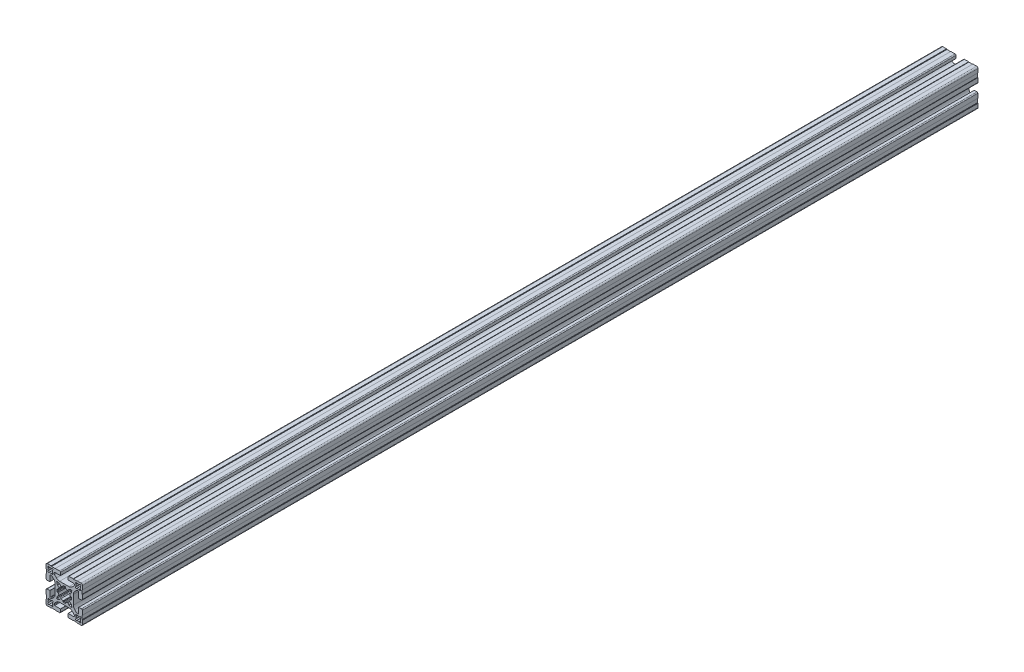
from build123d import *

# Parameters (mm, degrees)
RESSALTO_EXTRUS_O1_DEPTH = 490


with BuildPart() as part:
    # Esboço1 → Ressalto-extrusão1 (new body, symmetric)
    with BuildSketch(Plane.XY):
        with BuildLine():
            Line((4.14998475, -18.79998475), (4.14998475, -15.899980918))
            ThreePointArc((4.14998475, -15.899980918), (4.179274222, -15.829270089), (4.249985176, -15.799980918))
            Line((4.249985176, -15.799980918), (10.499997871, -15.800007531))
            ThreePointArc((10.499997871, -15.800007531), (10.853552638, -15.653561674), (11, -15.300007531))
            Line((11, -15.300007531), (11, -14.449747468))
            ThreePointArc((11, -14.449747468), (10.885819299, -13.87572232), (10.560660172, -13.389087297))
            Line((10.560660172, -13.389087297), (8.636038969, -11.464466094))
            ThreePointArc((8.636038969, -11.464466094), (7.013922225, -10.380602337), (5.100505063, -10))
            Line((5.100505063, -10), (0, -10))
            Line((0, -10), (-5.100505063, -10))
            ThreePointArc((-5.100505063, -10), (-7.013922225, -10.380602337), (-8.636038969, -11.464466094))
            Line((-8.636038969, -11.464466094), (-10.560660172, -13.389087297))
            ThreePointArc((-10.560660172, -13.389087297), (-10.885819299, -13.87572232), (-11, -14.449747468))
            Line((-11, -14.449747468), (-11, -15.300007531))
            ThreePointArc((-11, -15.300007531), (-10.853552638, -15.653561674), (-10.499997871, -15.800007531))
            Line((-10.499997871, -15.800007531), (-4.249985176, -15.799980918))
            ThreePointArc((-4.249985176, -15.799980918), (-4.179274222, -15.829270089), (-4.14998475, -15.899980918))
            Line((-4.14998475, -15.899980918), (-4.14998475, -18.79998475))
            ThreePointArc((-4.14998475, -18.79998475), (-4.442876463, -19.507090026), (-5.149980492, -19.79998475))
            Line((-5.149980492, -19.79998475), (-9.79996495, -19.80000455))
            Line((-9.79996495, -19.80000455), (-9.99998475, -19.59998475))
            Line((-9.99998475, -19.59998475), (-13.99998475, -19.59998475))
            Line((-13.99998475, -19.59998475), (-14.40000475, -20.00000475))
            Line((-14.40000475, -20.00000475), (-18.50000475, -20.00000475))
            ThreePointArc((-18.50000475, -20.00000475), (-19.560664922, -19.560664922), (-20.00000475, -18.50000475))
            Line((-20.00000475, -18.50000475), (-20.00000475, -14.40000475))
            Line((-20.00000475, -14.40000475), (-19.59998475, -13.99998475))
            Line((-19.59998475, -13.99998475), (-19.59998475, -9.99998475))
            Line((-19.59998475, -9.99998475), (-19.800004551, -9.799964949))
            Line((-19.800004551, -9.799964949), (-19.799984751, -5.149980488))
            ThreePointArc((-19.799984751, -5.149980488), (-19.507090026, -4.442876459), (-18.79998475, -4.149984746))
            Line((-18.79998475, -4.149984746), (-15.899980918, -4.149984746))
            ThreePointArc((-15.899980918, -4.149984746), (-15.829270089, -4.179274218), (-15.799980918, -4.249985172))
            Line((-15.799980918, -4.249985172), (-15.800007532, -10.499997871))
            ThreePointArc((-15.800007532, -10.499997871), (-15.653561675, -10.853552638), (-15.300007532, -11))
            Line((-15.300007532, -11), (-14.449747468, -11))
            ThreePointArc((-14.449747468, -11), (-13.87572232, -10.885819298), (-13.389087297, -10.560660171))
            Line((-13.389087297, -10.560660171), (-11.464466094, -8.636038969))
            ThreePointArc((-11.464466094, -8.636038969), (-10.380602337, -7.013922225), (-10, -5.100505063))
            Line((-10, -5.100505063), (-10, 0))
            Line((-10, 0), (-10, 5.100505064))
            ThreePointArc((-10, 5.100505064), (-10.380602337, 7.013922225), (-11.464466094, 8.63603897))
            Line((-11.464466094, 8.63603897), (-13.389087297, 10.560660172))
            ThreePointArc((-13.389087297, 10.560660172), (-13.87572232, 10.885819299), (-14.449747468, 11))
            Line((-14.449747468, 11), (-15.300007532, 11))
            ThreePointArc((-15.300007532, 11), (-15.653561675, 10.853552638), (-15.800007532, 10.499997871))
            Line((-15.800007532, 10.499997871), (-15.799980918, 4.249985172))
            ThreePointArc((-15.799980918, 4.249985172), (-15.829270089, 4.179274219), (-15.899980918, 4.149984747))
            Line((-15.899980918, 4.149984747), (-18.79998475, 4.149984747))
            ThreePointArc((-18.79998475, 4.149984747), (-19.507090026, 4.44287646), (-19.799984751, 5.149980488))
            Line((-19.799984751, 5.149980488), (-19.800004551, 9.79996495))
            Line((-19.800004551, 9.79996495), (-19.59998475, 9.999984751))
            Line((-19.59998475, 9.999984751), (-19.59998475, 13.999984751))
            Line((-19.59998475, 13.999984751), (-20.00000475, 14.400004751))
            Line((-20.00000475, 14.400004751), (-20.00000475, 18.500004751))
            ThreePointArc((-20.00000475, 18.500004751), (-19.560664922, 19.560664922), (-18.50000475, 20.000004751))
            Line((-18.50000475, 20.000004751), (-14.40000475, 20.000004751))
            Line((-14.40000475, 20.000004751), (-13.99998475, 19.599984751))
            Line((-13.99998475, 19.599984751), (-9.99998475, 19.599984751))
            Line((-9.99998475, 19.599984751), (-9.79996495, 19.800004551))
            Line((-9.79996495, 19.800004551), (-5.149980492, 19.799984751))
            ThreePointArc((-5.149980492, 19.799984751), (-4.442876463, 19.507090026), (-4.14998475, 18.799984751))
            Line((-4.14998475, 18.799984751), (-4.14998475, 15.899980918))
            ThreePointArc((-4.14998475, 15.899980918), (-4.179274222, 15.82927009), (-4.249985176, 15.799980918))
            Line((-4.249985176, 15.799980918), (-10.499997871, 15.800007531))
            ThreePointArc((-10.499997871, 15.800007531), (-10.853552638, 15.653561675), (-11, 15.300007531))
            Line((-11, 15.300007531), (-11, 14.449747469))
            ThreePointArc((-11, 14.449747469), (-10.885819299, 13.87572232), (-10.560660172, 13.389087297))
            Line((-10.560660172, 13.389087297), (-8.636038969, 11.464466095))
            ThreePointArc((-8.636038969, 11.464466095), (-7.013922225, 10.380602338), (-5.100505063, 10.000000001))
            Line((-5.100505063, 10.000000001), (0, 10.000000001))
            Line((0, 10.000000001), (5.100505063, 10.000000001))
            ThreePointArc((5.100505063, 10.000000001), (7.013922225, 10.380602338), (8.636038969, 11.464466095))
            Line((8.636038969, 11.464466095), (10.560660172, 13.389087297))
            ThreePointArc((10.560660172, 13.389087297), (10.885819299, 13.87572232), (11, 14.449747469))
            Line((11, 14.449747469), (11, 15.300007531))
            ThreePointArc((11, 15.300007531), (10.853552638, 15.653561675), (10.499997871, 15.800007531))
            Line((10.499997871, 15.800007531), (4.249985176, 15.799980918))
            ThreePointArc((4.249985176, 15.799980918), (4.179274222, 15.82927009), (4.14998475, 15.899980918))
            Line((4.14998475, 15.899980918), (4.14998475, 18.799984751))
            ThreePointArc((4.14998475, 18.799984751), (4.442876463, 19.507090026), (5.149980492, 19.799984751))
            Line((5.149980492, 19.799984751), (9.79996495, 19.800004551))
            Line((9.79996495, 19.800004551), (9.99998475, 19.599984751))
            Line((9.99998475, 19.599984751), (13.99998475, 19.599984751))
            Line((13.99998475, 19.599984751), (14.40000475, 20.000004751))
            Line((14.40000475, 20.000004751), (18.50000475, 20.000004751))
            ThreePointArc((18.50000475, 20.000004751), (19.560664922, 19.560664922), (20.00000475, 18.500004751))
            Line((20.00000475, 18.500004751), (20.00000475, 14.400004751))
            Line((20.00000475, 14.400004751), (19.59998475, 13.999984751))
            Line((19.59998475, 13.999984751), (19.59998475, 9.999984751))
            Line((19.59998475, 9.999984751), (19.800004551, 9.79996495))
            Line((19.800004551, 9.79996495), (19.799984751, 5.149980488))
            ThreePointArc((19.799984751, 5.149980488), (19.507090026, 4.44287646), (18.79998475, 4.149984747))
            Line((18.79998475, 4.149984747), (15.899980918, 4.149984747))
            ThreePointArc((15.899980918, 4.149984747), (15.829270089, 4.179274219), (15.799980918, 4.249985172))
            Line((15.799980918, 4.249985172), (15.800007532, 10.499997871))
            ThreePointArc((15.800007532, 10.499997871), (15.653561675, 10.853552638), (15.300007532, 11))
            Line((15.300007532, 11), (14.449747468, 11))
            ThreePointArc((14.449747468, 11), (13.87572232, 10.885819299), (13.389087297, 10.560660172))
            Line((13.389087297, 10.560660172), (11.464466094, 8.63603897))
            ThreePointArc((11.464466094, 8.63603897), (10.380602337, 7.013922225), (10, 5.100505064))
            Line((10, 5.100505064), (10, 0))
            Line((10, 0), (10, -5.100505063))
            ThreePointArc((10, -5.100505063), (10.380602337, -7.013922225), (11.464466094, -8.636038969))
            Line((11.464466094, -8.636038969), (13.389087297, -10.560660171))
            ThreePointArc((13.389087297, -10.560660171), (13.87572232, -10.885819298), (14.449747468, -11))
            Line((14.449747468, -11), (15.300007532, -11))
            ThreePointArc((15.300007532, -11), (15.653561675, -10.853552638), (15.800007532, -10.499997871))
            Line((15.800007532, -10.499997871), (15.799980918, -4.249985172))
            ThreePointArc((15.799980918, -4.249985172), (15.829270089, -4.179274218), (15.899980918, -4.149984746))
            Line((15.899980918, -4.149984746), (18.79998475, -4.149984746))
            ThreePointArc((18.79998475, -4.149984746), (19.507090026, -4.442876459), (19.799984751, -5.149980488))
            Line((19.799984751, -5.149980488), (19.800004551, -9.799964949))
            Line((19.800004551, -9.799964949), (19.59998475, -9.99998475))
            Line((19.59998475, -9.99998475), (19.59998475, -13.99998475))
            Line((19.59998475, -13.99998475), (20.00000475, -14.40000475))
            Line((20.00000475, -14.40000475), (20.00000475, -18.50000475))
            ThreePointArc((20.00000475, -18.50000475), (19.560664922, -19.560664922), (18.50000475, -20.00000475))
            Line((18.50000475, -20.00000475), (14.40000475, -20.00000475))
            Line((14.40000475, -20.00000475), (13.99998475, -19.59998475))
            Line((13.99998475, -19.59998475), (9.99998475, -19.59998475))
            Line((9.99998475, -19.59998475), (9.79996495, -19.80000455))
            Line((9.79996495, -19.80000455), (5.149980492, -19.79998475))
            ThreePointArc((5.149980492, -19.79998475), (4.442876463, -19.507090026), (4.14998475, -18.79998475))
        make_face()
        with BuildLine():
            Line((-5.31389005, -7.63550963), (-7.648765071, -8.261137506))
            ThreePointArc((-7.648765071, -8.261137506), (-8.131727984, -8.131727984), (-8.261137506, -7.64876507))
            Line((-8.261137506, -7.64876507), (-7.63550963, -5.313890049))
            ThreePointArc((-7.63550963, -5.313890049), (-7.568281523, -5.165514456), (-7.456927431, -5.046622902))
            Line((-7.456927431, -5.046622902), (-5.743958929, -3.73221594))
            ThreePointArc((-5.743958929, -3.73221594), (-6.328574798, -2.621381512), (-6.70066751, -1.422517109))
            Line((-6.70066751, -1.422517109), (-7.520425705, -1.314593895))
            ThreePointArc((-7.520425705, -1.314593895), (-7.812495975, -1.168604027), (-7.952173449, -0.873462896))
            ThreePointArc((-7.952173449, -0.873462896), (-8, 0), (-7.952173449, 0.873462896))
            ThreePointArc((-7.952173449, 0.873462896), (-7.812495975, 1.168604027), (-7.520425705, 1.314593895))
            Line((-7.520425705, 1.314593895), (-6.70066751, 1.422517109))
            ThreePointArc((-6.70066751, 1.422517109), (-6.328574798, 2.621381512), (-5.743958929, 3.73221594))
            Line((-5.743958929, 3.73221594), (-7.456927431, 5.046622902))
            ThreePointArc((-7.456927431, 5.046622902), (-7.568281523, 5.165514456), (-7.63550963, 5.313890049))
            Line((-7.63550963, 5.313890049), (-8.261137506, 7.64876507))
            ThreePointArc((-8.261137506, 7.64876507), (-8.131727984, 8.131727984), (-7.648765071, 8.261137506))
            Line((-7.648765071, 8.261137506), (-5.31389005, 7.63550963))
            ThreePointArc((-5.31389005, 7.63550963), (-5.165514456, 7.568281523), (-5.046622902, 7.456927431))
            Line((-5.046622902, 7.456927431), (-3.73221594, 5.743958929))
            ThreePointArc((-3.73221594, 5.743958929), (-2.621381512, 6.328574798), (-1.422517109, 6.70066751))
            Line((-1.422517109, 6.70066751), (-1.314593895, 7.520425705))
            ThreePointArc((-1.314593895, 7.520425705), (-1.168604027, 7.812495975), (-0.873462896, 7.952173449))
            ThreePointArc((-0.873462896, 7.952173449), (0, 8), (0.873462896, 7.952173449))
            ThreePointArc((0.873462896, 7.952173449), (1.168604027, 7.812495975), (1.314593895, 7.520425705))
            Line((1.314593895, 7.520425705), (1.422517109, 6.70066751))
            ThreePointArc((1.422517109, 6.70066751), (2.621381512, 6.328574798), (3.73221594, 5.743958929))
            Line((3.73221594, 5.743958929), (5.046622902, 7.456927431))
            ThreePointArc((5.046622902, 7.456927431), (5.165514456, 7.568281523), (5.31389005, 7.63550963))
            Line((5.31389005, 7.63550963), (7.648765071, 8.261137506))
            ThreePointArc((7.648765071, 8.261137506), (8.131727984, 8.131727984), (8.261137506, 7.64876507))
            Line((8.261137506, 7.64876507), (7.63550963, 5.313890049))
            ThreePointArc((7.63550963, 5.313890049), (7.568281523, 5.165514456), (7.456927431, 5.046622902))
            Line((7.456927431, 5.046622902), (5.743958929, 3.73221594))
            ThreePointArc((5.743958929, 3.73221594), (6.328574798, 2.621381512), (6.70066751, 1.422517109))
            Line((6.70066751, 1.422517109), (7.520425705, 1.314593895))
            ThreePointArc((7.520425705, 1.314593895), (7.812495975, 1.168604027), (7.952173449, 0.873462896))
            ThreePointArc((7.952173449, 0.873462896), (8, 0), (7.952173449, -0.873462896))
            ThreePointArc((7.952173449, -0.873462896), (7.812495975, -1.168604027), (7.520425705, -1.314593895))
            Line((7.520425705, -1.314593895), (6.70066751, -1.422517109))
            ThreePointArc((6.70066751, -1.422517109), (6.328574798, -2.621381512), (5.743958929, -3.73221594))
            Line((5.743958929, -3.73221594), (7.456927431, -5.046622902))
            ThreePointArc((7.456927431, -5.046622902), (7.568281523, -5.165514456), (7.63550963, -5.313890049))
            Line((7.63550963, -5.313890049), (8.261137506, -7.64876507))
            ThreePointArc((8.261137506, -7.64876507), (8.131727984, -8.131727984), (7.648765071, -8.261137506))
            Line((7.648765071, -8.261137506), (5.31389005, -7.63550963))
            ThreePointArc((5.31389005, -7.63550963), (5.165514456, -7.568281523), (5.046622902, -7.456927431))
            Line((5.046622902, -7.456927431), (3.73221594, -5.743958929))
            ThreePointArc((3.73221594, -5.743958929), (2.621381512, -6.328574798), (1.422517109, -6.70066751))
            Line((1.422517109, -6.70066751), (1.314593895, -7.520425705))
            ThreePointArc((1.314593895, -7.520425705), (1.168604027, -7.812495975), (0.873462896, -7.952173449))
            ThreePointArc((0.873462896, -7.952173449), (0, -8), (-0.873462896, -7.952173449))
            ThreePointArc((-0.873462896, -7.952173449), (-1.168604027, -7.812495975), (-1.314593895, -7.520425705))
            Line((-1.314593895, -7.520425705), (-1.422517109, -6.70066751))
            ThreePointArc((-1.422517109, -6.70066751), (-2.621381512, -6.328574798), (-3.73221594, -5.743958929))
            Line((-3.73221594, -5.743958929), (-5.046622902, -7.456927431))
            ThreePointArc((-5.046622902, -7.456927431), (-5.165514456, -7.568281523), (-5.31389005, -7.63550963))
        make_face(mode=Mode.SUBTRACT)
        with BuildLine():
            Line((-17.857240871, 16.796580699), (-17.416672281, 16.356012109))
            ThreePointArc((-17.416672281, 16.356012109), (-17.7, 15.2), (-17.416672281, 14.04398789))
            Line((-17.416672281, 14.04398789), (-17.857240871, 13.603419301))
            ThreePointArc((-17.857240871, 13.603419301), (-17.857240871, 12.542759129), (-16.796580699, 12.542759129))
            Line((-16.796580699, 12.542759129), (-16.35601211, 12.983327719))
            ThreePointArc((-16.35601211, 12.983327719), (-15.2, 12.7), (-14.04398789, 12.983327719))
            Line((-14.04398789, 12.983327719), (-13.603419301, 12.542759129))
            ThreePointArc((-13.603419301, 12.542759129), (-12.542759129, 12.542759129), (-12.542759129, 13.603419301))
            Line((-12.542759129, 13.603419301), (-12.983327719, 14.04398789))
            ThreePointArc((-12.983327719, 14.04398789), (-12.7, 15.2), (-12.983327719, 16.356012109))
            Line((-12.983327719, 16.356012109), (-12.542759081, 16.796580747))
            ThreePointArc((-12.542759081, 16.796580747), (-12.542759081, 17.857240919), (-13.603419253, 17.857240919))
            Line((-13.603419253, 17.857240919), (-14.04398789, 17.416672281))
            ThreePointArc((-14.04398789, 17.416672281), (-15.2, 17.7), (-16.35601211, 17.416672281))
            Line((-16.35601211, 17.416672281), (-16.796580699, 17.857240871))
            ThreePointArc((-16.796580699, 17.857240871), (-17.857240871, 17.857240871), (-17.857240871, 16.796580699))
        make_face(mode=Mode.SUBTRACT)
        with BuildLine():
            Line((17.416672281, 14.04398789), (17.857240871, 13.603419301))
            ThreePointArc((17.857240871, 13.603419301), (17.857240871, 12.542759129), (16.796580699, 12.542759129))
            Line((16.796580699, 12.542759129), (16.35601211, 12.983327719))
            ThreePointArc((16.35601211, 12.983327719), (15.2, 12.7), (14.043987891, 12.983327719))
            Line((14.043987891, 12.983327719), (13.603419301, 12.542759129))
            ThreePointArc((13.603419301, 12.542759129), (12.542759129, 12.542759129), (12.542759129, 13.603419301))
            Line((12.542759129, 13.603419301), (12.983327719, 14.04398789))
            ThreePointArc((12.983327719, 14.04398789), (12.7, 15.2), (12.983327719, 16.356012109))
            Line((12.983327719, 16.356012109), (12.542759081, 16.796580747))
            ThreePointArc((12.542759081, 16.796580747), (12.542759081, 17.857240919), (13.603419253, 17.857240919))
            Line((13.603419253, 17.857240919), (14.043987891, 17.416672281))
            ThreePointArc((14.043987891, 17.416672281), (15.2, 17.7), (16.35601211, 17.416672281))
            Line((16.35601211, 17.416672281), (16.796580699, 17.857240871))
            ThreePointArc((16.796580699, 17.857240871), (17.857240871, 17.857240871), (17.857240871, 16.796580699))
            Line((17.857240871, 16.796580699), (17.416672281, 16.356012109))
            ThreePointArc((17.416672281, 16.356012109), (17.7, 15.2), (17.416672281, 14.04398789))
        make_face(mode=Mode.SUBTRACT)
        with BuildLine():
            Line((-17.416672281, -14.04398789), (-17.857240871, -13.603419301))
            ThreePointArc((-17.857240871, -13.603419301), (-17.857240871, -12.542759129), (-16.796580699, -12.542759129))
            Line((-16.796580699, -12.542759129), (-16.35601211, -12.983327719))
            ThreePointArc((-16.35601211, -12.983327719), (-15.2, -12.7), (-14.04398789, -12.983327719))
            Line((-14.04398789, -12.983327719), (-13.603419301, -12.542759129))
            ThreePointArc((-13.603419301, -12.542759129), (-12.542759129, -12.542759129), (-12.542759129, -13.603419301))
            Line((-12.542759129, -13.603419301), (-12.983327719, -14.04398789))
            ThreePointArc((-12.983327719, -14.04398789), (-12.7, -15.2), (-12.983327719, -16.35601211))
            Line((-12.983327719, -16.35601211), (-12.542759081, -16.796580747))
            ThreePointArc((-12.542759081, -16.796580747), (-12.542759081, -17.857240919), (-13.603419253, -17.857240919))
            Line((-13.603419253, -17.857240919), (-14.04398789, -17.416672281))
            ThreePointArc((-14.04398789, -17.416672281), (-15.2, -17.7), (-16.35601211, -17.416672281))
            Line((-16.35601211, -17.416672281), (-16.796580699, -17.857240871))
            ThreePointArc((-16.796580699, -17.857240871), (-17.857240871, -17.857240871), (-17.857240871, -16.796580699))
            Line((-17.857240871, -16.796580699), (-17.416672281, -16.35601211))
            ThreePointArc((-17.416672281, -16.35601211), (-17.7, -15.2), (-17.416672281, -14.04398789))
        make_face(mode=Mode.SUBTRACT)
        with BuildLine():
            Line((17.857240871, -16.796580699), (17.416672281, -16.35601211))
            ThreePointArc((17.416672281, -16.35601211), (17.7, -15.2), (17.416672281, -14.04398789))
            Line((17.416672281, -14.04398789), (17.857240871, -13.603419301))
            ThreePointArc((17.857240871, -13.603419301), (17.857240871, -12.542759129), (16.796580699, -12.542759129))
            Line((16.796580699, -12.542759129), (16.35601211, -12.983327719))
            ThreePointArc((16.35601211, -12.983327719), (15.2, -12.7), (14.043987891, -12.983327719))
            Line((14.043987891, -12.983327719), (13.603419301, -12.542759129))
            ThreePointArc((13.603419301, -12.542759129), (12.542759129, -12.542759129), (12.542759129, -13.603419301))
            Line((12.542759129, -13.603419301), (12.983327719, -14.04398789))
            ThreePointArc((12.983327719, -14.04398789), (12.7, -15.2), (12.983327719, -16.35601211))
            Line((12.983327719, -16.35601211), (12.542759081, -16.796580747))
            ThreePointArc((12.542759081, -16.796580747), (12.542759081, -17.857240919), (13.603419253, -17.857240919))
            Line((13.603419253, -17.857240919), (14.043987891, -17.416672281))
            ThreePointArc((14.043987891, -17.416672281), (15.2, -17.7), (16.35601211, -17.416672281))
            Line((16.35601211, -17.416672281), (16.796580699, -17.857240871))
            ThreePointArc((16.796580699, -17.857240871), (17.857240871, -17.857240871), (17.857240871, -16.796580699))
        make_face(mode=Mode.SUBTRACT)
    extrude(amount=RESSALTO_EXTRUS_O1_DEPTH, both=True)


solid = part.part
